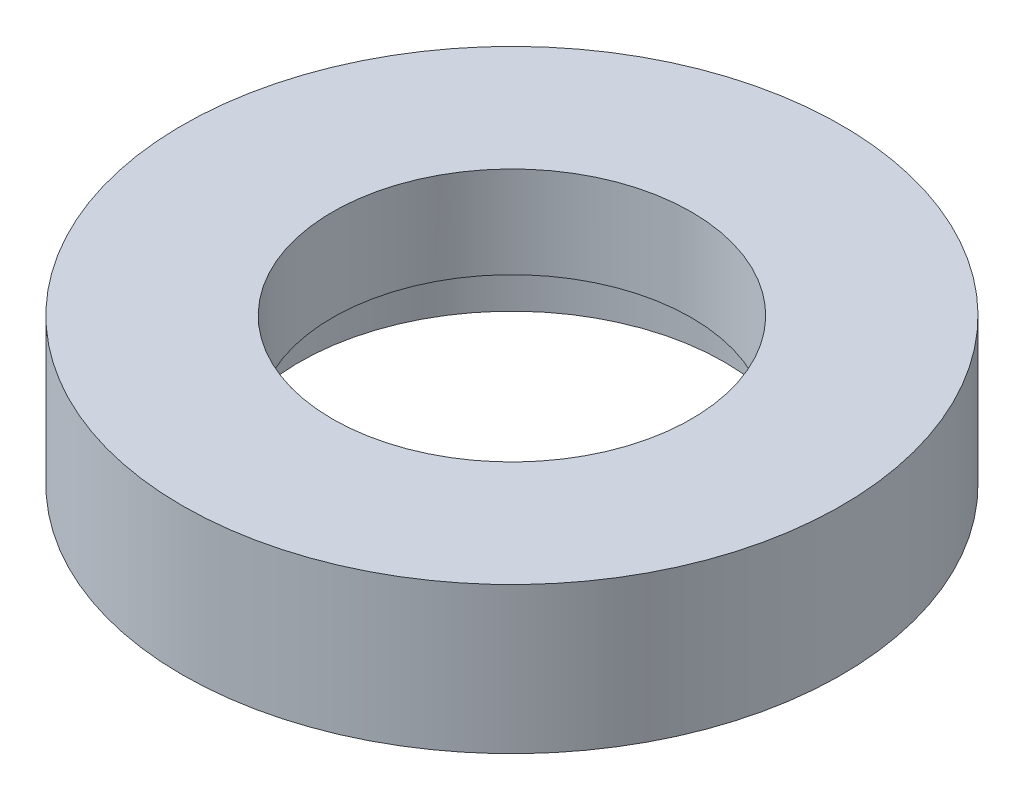
from build123d import *

# Parameters (mm, degrees)
SKETCH1_R           = 4.5
SKETCH1_R_2         = 2.45
BOSS_EXTRUDE1_DEPTH = 2
SKETCH2_R           = 2.9
CUT_EXTRUDE1_DEPTH  = 0.75


with BuildPart() as part:
    # Sketch1 → Boss-Extrude1 (new body)
    with BuildSketch(Plane(origin=(0, 0, 0), x_dir=(1, 0, 0), z_dir=(0, 1, 0))):
        Circle(SKETCH1_R)
        Circle(SKETCH1_R_2, mode=Mode.SUBTRACT)
    extrude(amount=BOSS_EXTRUDE1_DEPTH)

    # Sketch2 → Cut-Extrude1 (cut)
    with BuildSketch(Plane(origin=(0, 0, 0), x_dir=(-1, 0, 0), z_dir=(0, -1, 0))):
        Circle(SKETCH2_R)
    extrude(amount=-CUT_EXTRUDE1_DEPTH, mode=Mode.SUBTRACT)


solid = part.part
